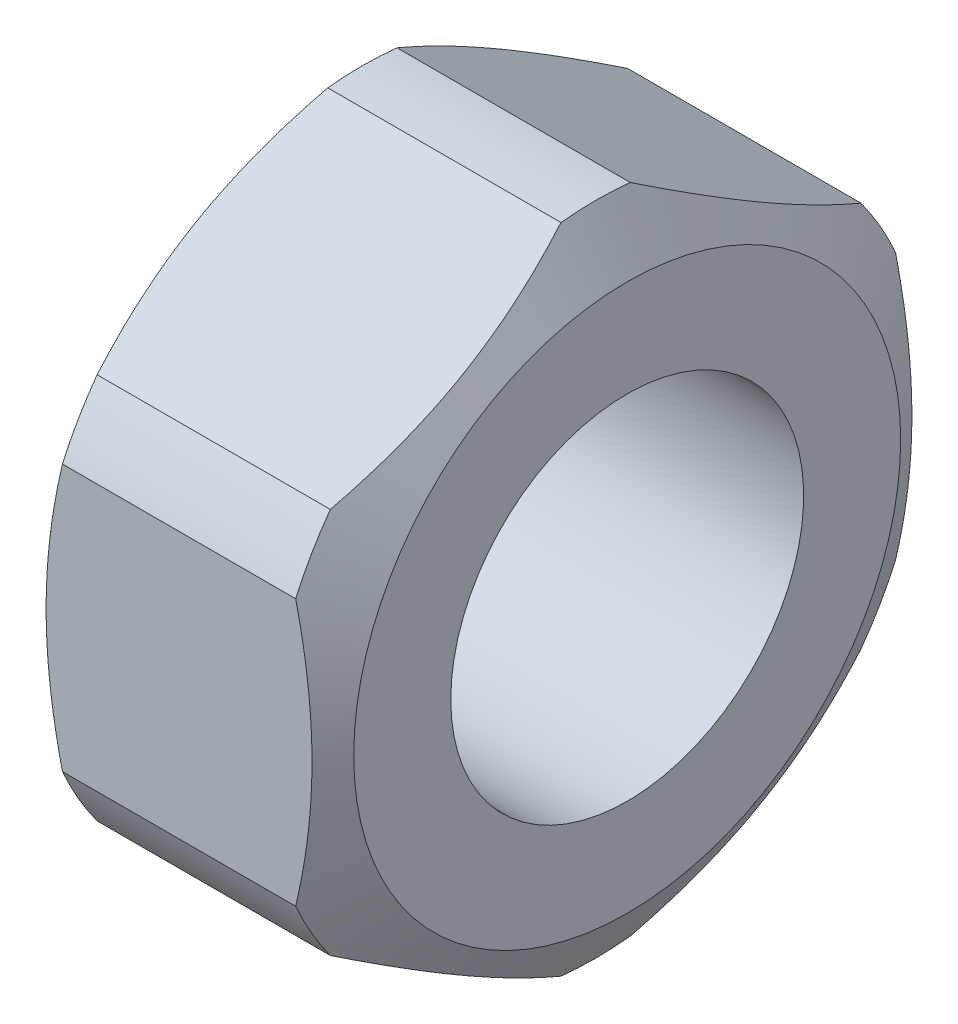
from build123d import *

# Parameters (mm, degrees)
SKETCH_2_OUTSIDE_W  = 26.122
SKETCH_2_OUTSIDE_H  = 26.122
CUT_EXTRUDE_1_DEPTH = 9.4


with BuildPart() as part:
    # Эскиз1 → Повернуть1 (revolve)
    with BuildSketch(Plane.XY):
        Polygon((4.2, 5), (-4.2, 5), (-4.2, 7.75), (-3.305107083, 9.3), (3.305107083, 9.3), (4.2, 7.75), align=None)
    revolve(axis=Axis((-345.378129483, 0, 0), (1, 0, 0)))

    # Эскиз2 outside → Вырез-Вытянуть1 (cut, through all)
    with BuildSketch(Plane.ZY.offset(4.2)):
        Rectangle(SKETCH_2_OUTSIDE_W, SKETCH_2_OUTSIDE_H)
        Polygon((0, -9.814954576), (8.5, -4.907477288), (8.5, 4.907477288), (0, 9.814954576), (-8.5, 4.907477288), (-8.5, -4.907477288), align=None, mode=Mode.SUBTRACT)
    extrude(amount=-CUT_EXTRUDE_1_DEPTH, mode=Mode.SUBTRACT)


solid = part.part
